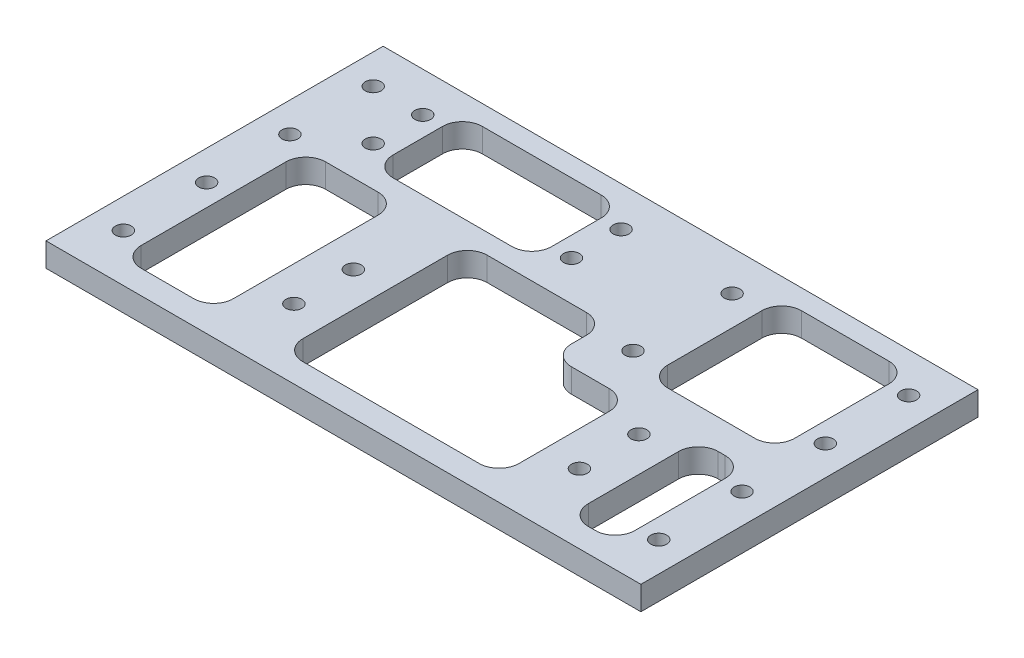
from build123d import *

# Parameters (mm, degrees)
SKETCH1_W           = 300
SKETCH1_H           = 170
BOSS_EXTRUDE1_DEPTH = 12
SKETCH2_R           = 4
CUT_EXTRUDE1_DEPTH  = 13
SKETCH4_R           = 4
CUT_EXTRUDE2_DEPTH  = 13
SKETCH5_R           = 4
CUT_EXTRUDE3_DEPTH  = 13
SKETCH6_W           = 46.5
SKETCH6_H           = 93
SKETCH6_W_2         = 80
SKETCH6_H_2         = 45
SKETCH6_W_3         = 64
SKETCH6_H_3         = 67.5
SKETCH6_W_4         = 23.5
SKETCH6_H_4         = 65.5
CUT_EXTRUDE4_DEPTH  = 13
FILLET1_R           = 10


with BuildPart() as part:
    # Sketch1 → Boss-Extrude1 (new body)
    with BuildSketch(Plane(origin=(0, 0, 0), x_dir=(1, 0, 0), z_dir=(0, 1, 0))):
        Rectangle(SKETCH1_W, SKETCH1_H)
    extrude(amount=BOSS_EXTRUDE1_DEPTH)

    # Sketch2 → Cut-Extrude1 (cut, through all)
    with BuildSketch(Plane(origin=(0, 12, 0), x_dir=(1, 0, 0), z_dir=(0, 1, 0))):
        with Locations((-135, 65)):
            Circle(SKETCH2_R)
        with Locations((-135, 23)):
            Circle(SKETCH2_R)
        with Locations((-135, -19)):
            Circle(SKETCH2_R)
        with Locations((-135, -61)):
            Circle(SKETCH2_R)
        with Locations((-135, -103)):
            Circle(SKETCH2_R)
        with Locations((-135, -145)):
            Circle(SKETCH2_R)
    cut_extrude1 = extrude(amount=-CUT_EXTRUDE1_DEPTH, mode=Mode.SUBTRACT)

    # Mirror1: Cut-Extrude1 across plane
    add(cut_extrude1.mirror(Plane(origin=(0, 0, 0), x_dir=(0, 0, 1), z_dir=(1, 0, 0))), mode=Mode.SUBTRACT)

    # Sketch4 → Cut-Extrude2 (cut, through all)
    with BuildSketch(Plane(origin=(0, 12, 0), x_dir=(1, 0, 0), z_dir=(0, 1, 0))):
        with Locations((-110, 65)):
            Circle(SKETCH4_R)
        with Locations((-10, 65)):
            Circle(SKETCH4_R)
        with Locations((-110, 40)):
            Circle(SKETCH4_R)
        with Locations((-10, 40)):
            Circle(SKETCH4_R)
        with Locations((46, 65)):
            Circle(SKETCH4_R)
        with Locations((46, 15)):
            Circle(SKETCH4_R)
    extrude(amount=-CUT_EXTRUDE2_DEPTH, mode=Mode.SUBTRACT)

    # Sketch5 → Cut-Extrude3 (cut, through all)
    with BuildSketch(Plane(origin=(0, 12, 0), x_dir=(1, 0, 0), z_dir=(0, 1, 0))):
        with Locations((-60, -20)):
            Circle(SKETCH5_R)
        with Locations((-60, -50)):
            Circle(SKETCH5_R)
        with Locations((84, -20)):
            Circle(SKETCH5_R)
        with Locations((84, -50)):
            Circle(SKETCH5_R)
    extrude(amount=-CUT_EXTRUDE3_DEPTH, mode=Mode.SUBTRACT)

    # Sketch6 → Cut-Extrude4 (cut, through all)
    with BuildSketch(Plane(origin=(0, 12, 0), x_dir=(1, 0, 0), z_dir=(0, 1, 0))):
        with Locations((-100.75, -26.5)):
            Rectangle(SKETCH6_W, SKETCH6_H)
        Polygon((27.5, 20), (-42.5, 20), (-42.5, -73), (66.5, -73), (66.5, -7.5), (27.5, -7.5), align=None)
        with Locations((-60, 52.5)):
            Rectangle(SKETCH6_W_2, SKETCH6_H_2)
        with Locations((93, 41.25)):
            Rectangle(SKETCH6_W_3, SKETCH6_H_3)
        with Locations((113.25, -40.25)):
            Rectangle(SKETCH6_W_4, SKETCH6_H_4)
    extrude(amount=-CUT_EXTRUDE4_DEPTH, mode=Mode.SUBTRACT)

    # Fillet1
    fillet1_edges = [part.edges().sort_by_distance(p)[0] for p in [
        (-42.5, 6, 73),
        (-42.5, 6, -20),
        (27.5, 6, -20),
        (27.5, 6, 7.5),
        (66.5, 6, 7.5),
        (66.5, 6, 73),
        (-20, 6, -75),
        (-20, 6, -30),
        (-100, 6, -30),
        (-100, 6, -75),
        (125, 6, -75),
        (125, 6, -7.5),
        (61, 6, -7.5),
        (61, 6, -75),
        (125, 6, 7.5),
        (125, 6, 73),
        (101.5, 6, 73),
        (101.5, 6, 7.5),
        (-124, 6, 73),
        (-124, 6, -20),
        (-77.5, 6, -20),
        (-77.5, 6, 73),
    ]]
    fillet(fillet1_edges, radius=FILLET1_R)


solid = part.part
